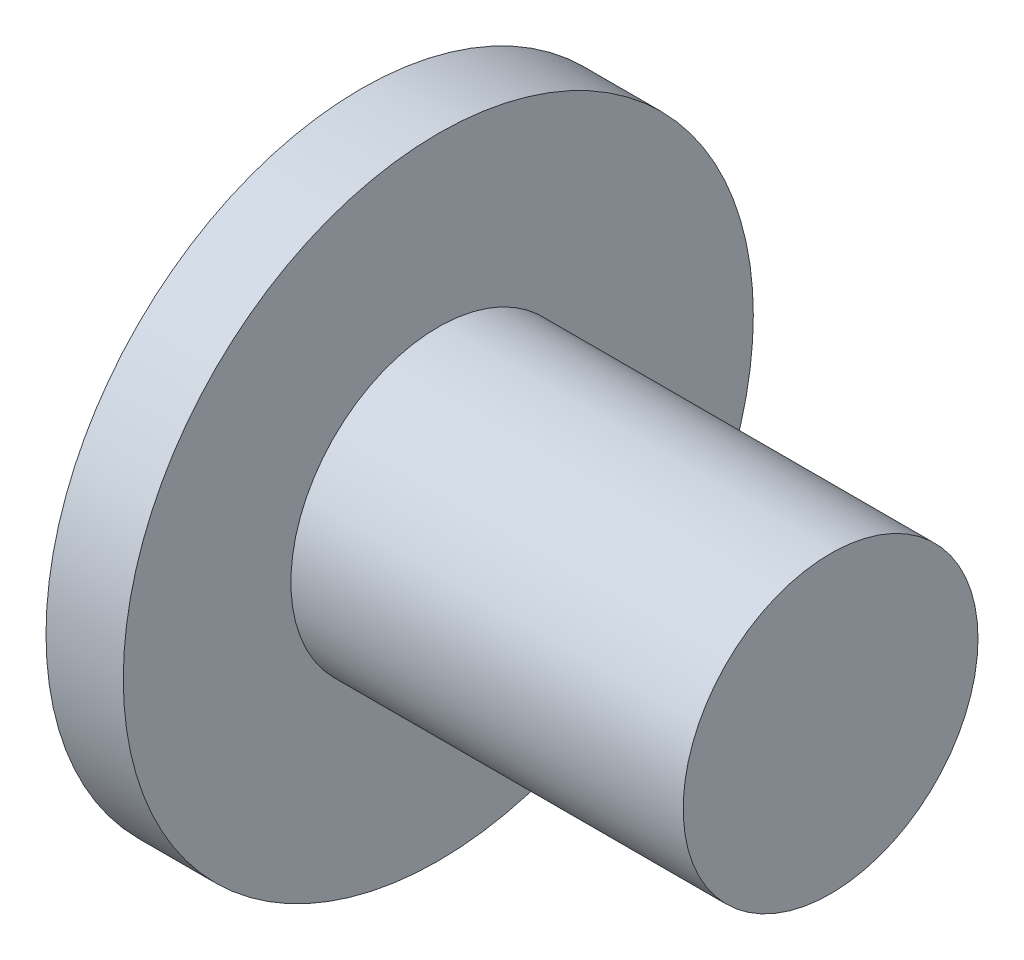
from build123d import *

# Parameters (mm, degrees)
SKETCH1_R           = 6.731
BOSS_EXTRUDE1_DEPTH = 1.651
SKETCH2_R           = 3.1496
BOSS_EXTRUDE2_DEPTH = 8.382


with BuildPart() as part:
    # Sketch1 → Boss-Extrude1 (new body)
    with BuildSketch(Plane(origin=(0, 0, 0), x_dir=(0, 0, -1), z_dir=(1, 0, 0))):
        Circle(SKETCH1_R)
    extrude(amount=BOSS_EXTRUDE1_DEPTH)

    # Sketch2 → Boss-Extrude2 (add)
    with BuildSketch(Plane(origin=(1.651, 0, 0), x_dir=(0, 0, -1), z_dir=(1, 0, 0))):
        Circle(SKETCH2_R)
    extrude(amount=BOSS_EXTRUDE2_DEPTH)


solid = part.part
